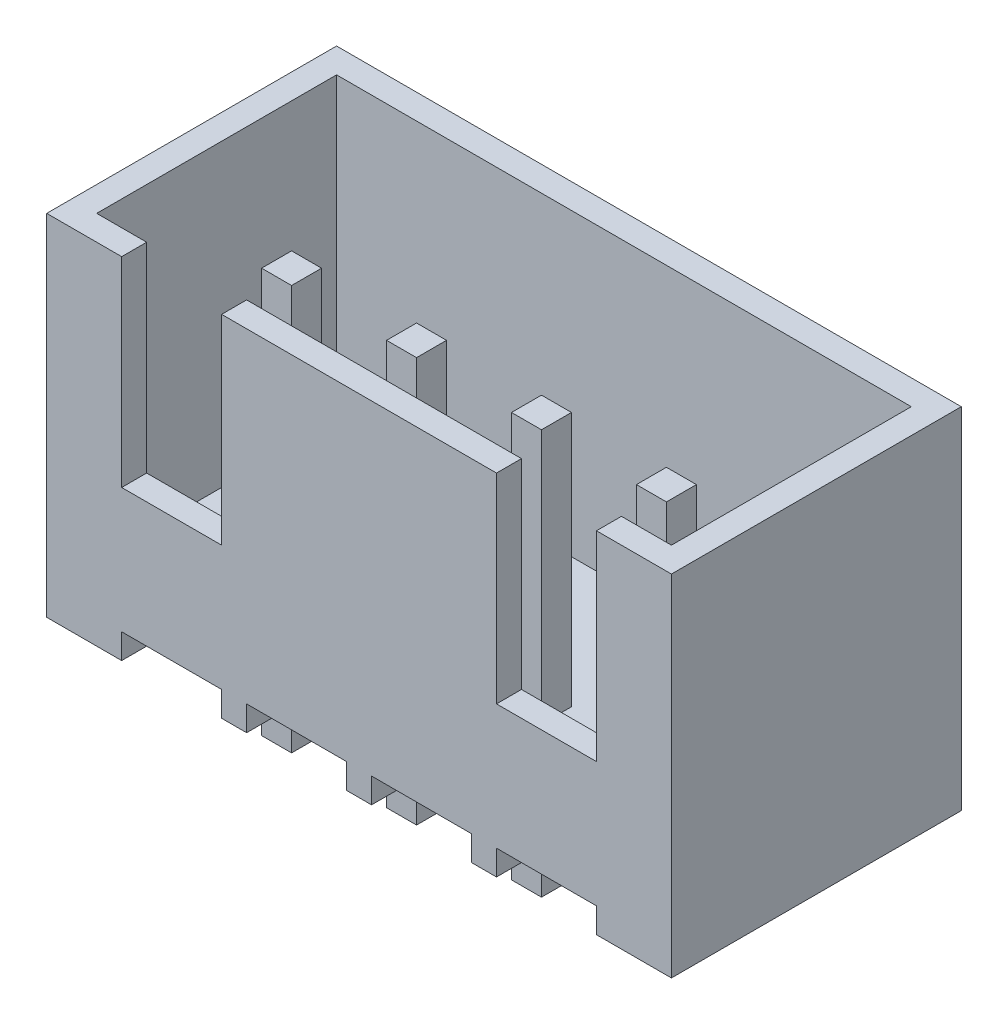
from build123d import *

# Parameters (mm, degrees)
EXTRUDE_1_DEPTH      = 5.8
SKETCH_2_W           = 11.5
SKETCH_2_H           = 4.8
CUT_EXTRUDE_1_DEPTH  = 6
SKETCH_3_W           = 0.6
SKETCH_3_H           = 0.6
EXTRUDE_2_DEPTH      = 2
EXTRUDE_2_DEPTH_BACK = 6.1
SKETCH_5_W           = 2
SKETCH_5_H           = 4
CUT_EXTRUDE_2_DEPTH  = 1


with BuildPart() as part:
    # 草图1 → 凸台-拉伸1 (new body)
    with BuildSketch(Plane.XY):
        Polygon((4, 0), (4, 0.5), (6, 0.5), (6, 0), (6.5, 0), (6.5, 0.5), (8.5, 0.5), (8.5, 0), (9, 0), (9, 0.5), (11, 0.5), (11, 0), (12.5, 0), (12.5, 7), (0, 7), (0, 0), (1.5, 0), (1.5, 0.5), (3.5, 0.5), (3.5, 0), align=None)
    extrude(amount=EXTRUDE_1_DEPTH)

    # 草图2 → 切除-拉伸1 (cut)
    with BuildSketch(Plane(origin=(0, 7, 0), x_dir=(1, 0, 0), z_dir=(0, 1, 0))):
        with Locations((6.25, -2.9)):
            Rectangle(SKETCH_2_W, SKETCH_2_H)
    extrude(amount=-CUT_EXTRUDE_1_DEPTH, mode=Mode.SUBTRACT)

    # 草图3 → 凸台-拉伸2 (add, two sides)
    with BuildSketch(Plane.XZ) as extrude_2_sk:
        with Locations((5, 3.4)):
            Rectangle(SKETCH_3_W, SKETCH_3_H)
        with Locations((7.5, 3.4)):
            Rectangle(SKETCH_3_W, SKETCH_3_H)
        with Locations((2.5, 3.4)):
            Rectangle(SKETCH_3_W, SKETCH_3_H)
        with Locations((10, 3.4)):
            Rectangle(SKETCH_3_W, SKETCH_3_H)
    extrude(amount=EXTRUDE_2_DEPTH)
    extrude(extrude_2_sk.sketch, amount=-EXTRUDE_2_DEPTH_BACK)

    # 草图5 → 切除-拉伸2 (cut)
    with BuildSketch(Plane.XY.offset(5.8)):
        with Locations((2.5, 5)):
            Rectangle(SKETCH_5_W, SKETCH_5_H)
        with Locations((10, 5)):
            Rectangle(SKETCH_5_W, SKETCH_5_H)
    extrude(amount=-CUT_EXTRUDE_2_DEPTH, mode=Mode.SUBTRACT)


solid = part.part
